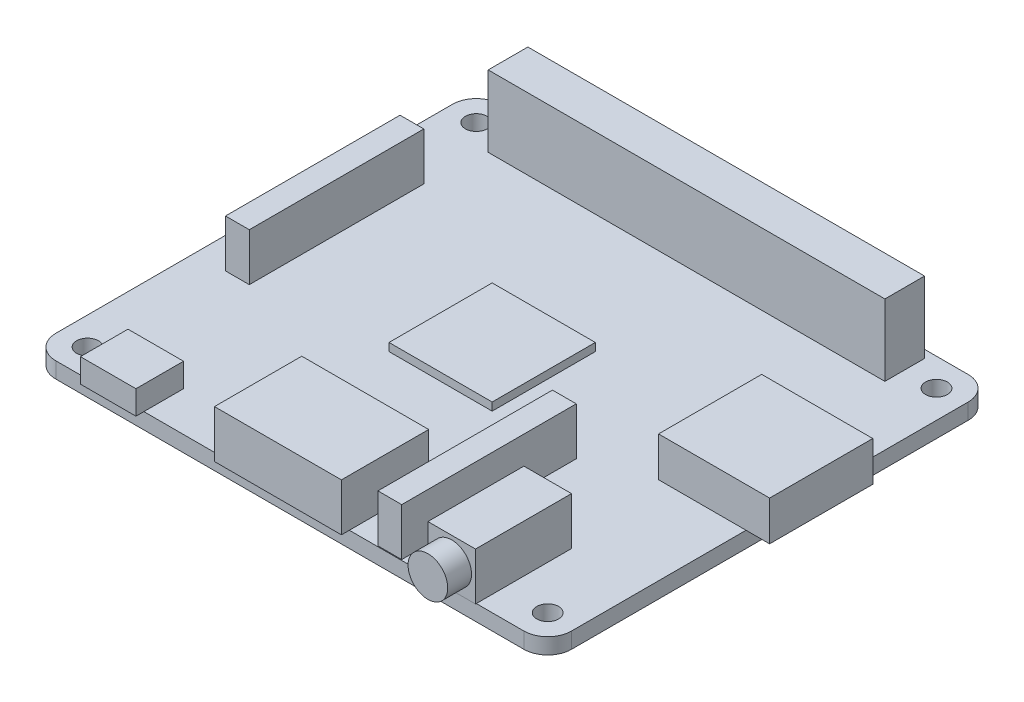
from build123d import *

# Parameters (mm, degrees)
SKETCH1_W            = 65
SKETCH1_H            = 56
BOSS_EXTRUDE1_DEPTH  = 2
SKETCH2_R            = 1.375
CUT_EXTRUDE1_DEPTH   = 2
FILLET1_R            = 3
FILLET2_R            = 3
FILLET3_R            = 3
FILLET4_R            = 3
SKETCH3_W            = 50
SKETCH3_H            = 5
BOSS_EXTRUDE2_DEPTH  = 9
SKETCH4_W            = 3
SKETCH4_H            = 22
BOSS_EXTRUDE3_DEPTH  = 6
SKETCH5_W            = 14
SKETCH5_H            = 13
BOSS_EXTRUDE4_DEPTH  = 5
SKETCH6_W            = 6
SKETCH6_H            = 12.1
BOSS_EXTRUDE5_DEPTH  = 6
SKETCH7_R            = 2.5
BOSS_EXTRUDE6_DEPTH  = 3
SKETCH8_W            = 3
SKETCH8_H            = 22
BOSS_EXTRUDE7_DEPTH  = 6
SKETCH9_W            = 16
SKETCH9_H            = 11
BOSS_EXTRUDE8_DEPTH  = 6
SKETCH10_W           = 7
SKETCH10_H           = 6
BOSS_EXTRUDE9_DEPTH  = 3
SKETCH11_W           = 17
SKETCH11_H           = 13
BOSS_EXTRUDE10_DEPTH = 2
SKETCH12_W           = 13
SKETCH12_H           = 13
BOSS_EXTRUDE11_DEPTH = 1


with BuildPart() as part:
    # Sketch1 → Boss-Extrude1 (new body)
    with BuildSketch(Plane(origin=(0, 0, 0), x_dir=(1, 0, 0), z_dir=(0, 1, 0))):
        Rectangle(SKETCH1_W, SKETCH1_H)
    extrude(amount=BOSS_EXTRUDE1_DEPTH)

    # Sketch2 → Cut-Extrude1 (cut)
    with BuildSketch(Plane(origin=(0, 2, 0), x_dir=(1, 0, 0), z_dir=(0, 1, 0))):
        with Locations((-29, -24.5)):
            Circle(SKETCH2_R)
        with Locations((-29, 24.5)):
            Circle(SKETCH2_R)
        with Locations((29, -24.5)):
            Circle(SKETCH2_R)
        with Locations((29, 24.5)):
            Circle(SKETCH2_R)
    extrude(amount=-CUT_EXTRUDE1_DEPTH, mode=Mode.SUBTRACT)

    # Fillet1
    fillet1_edges = [part.edges().sort_by_distance(p)[0] for p in [
        (-32.5, 1, 28),
    ]]
    fillet(fillet1_edges, radius=FILLET1_R)

    # Fillet2
    fillet2_edges = [part.edges().sort_by_distance(p)[0] for p in [
        (32.5, 1, 28),
    ]]
    fillet(fillet2_edges, radius=FILLET2_R)

    # Fillet3
    fillet3_edges = [part.edges().sort_by_distance(p)[0] for p in [
        (32.5, 1, -28),
    ]]
    fillet(fillet3_edges, radius=FILLET3_R)

    # Fillet4
    fillet4_edges = [part.edges().sort_by_distance(p)[0] for p in [
        (-32.5, 1, -28),
    ]]
    fillet(fillet4_edges, radius=FILLET4_R)

    # Sketch3 → Boss-Extrude2 (add)
    with BuildSketch(Plane(origin=(0, 2, 0), x_dir=(1, 0, 0), z_dir=(0, 1, 0))):
        with Locations((0, 24.5)):
            Rectangle(SKETCH3_W, SKETCH3_H)
    extrude(amount=BOSS_EXTRUDE2_DEPTH)

    # Sketch4 → Boss-Extrude3 (add)
    with BuildSketch(Plane(origin=(0, 2, 0), x_dir=(1, 0, 0), z_dir=(0, 1, 0))):
        with Locations((-27.111657831, 3.5)):
            Rectangle(SKETCH4_W, SKETCH4_H)
    extrude(amount=BOSS_EXTRUDE3_DEPTH)

    # Sketch5 → Boss-Extrude4 (add)
    with BuildSketch(Plane(origin=(0, 2, 0), x_dir=(1, 0, 0), z_dir=(0, 1, 0))):
        with Locations((28.469915967, 3.5)):
            Rectangle(SKETCH5_W, SKETCH5_H)
    extrude(amount=BOSS_EXTRUDE4_DEPTH)

    # Sketch6 → Boss-Extrude5 (add)
    with BuildSketch(Plane(origin=(0, 2, 0), x_dir=(1, 0, 0), z_dir=(0, 1, 0))):
        with Locations((20.5, -22.05)):
            Rectangle(SKETCH6_W, SKETCH6_H)
    extrude(amount=BOSS_EXTRUDE5_DEPTH)

    # Sketch7 → Boss-Extrude6 (add)
    with BuildSketch(Plane.XY.offset(28.1)):
        with Locations((20.5, 5)):
            Circle(SKETCH7_R)
    extrude(amount=BOSS_EXTRUDE6_DEPTH)

    # Sketch8 → Boss-Extrude7 (add)
    with BuildSketch(Plane(origin=(0, 2, 0), x_dir=(1, 0, 0), z_dir=(0, 1, 0))):
        with Locations((12.5, -16.9)):
            Rectangle(SKETCH8_W, SKETCH8_H)
    extrude(amount=BOSS_EXTRUDE7_DEPTH)

    # Sketch9 → Boss-Extrude8 (add)
    with BuildSketch(Plane(origin=(0, 2, 0), x_dir=(1, 0, 0), z_dir=(0, 1, 0))):
        with Locations((-0.5, -23.5)):
            Rectangle(SKETCH9_W, SKETCH9_H)
    extrude(amount=BOSS_EXTRUDE8_DEPTH)

    # Sketch10 → Boss-Extrude9 (add)
    with BuildSketch(Plane(origin=(0, 2, 0), x_dir=(1, 0, 0), z_dir=(0, 1, 0))):
        with Locations((-21.9, -26)):
            Rectangle(SKETCH10_W, SKETCH10_H)
    extrude(amount=BOSS_EXTRUDE9_DEPTH)

    # Sketch11 → Boss-Extrude10 (add)
    with BuildSketch(Plane.XZ):
        with Locations((-26, -1.5)):
            Rectangle(SKETCH11_W, SKETCH11_H)
    extrude(amount=BOSS_EXTRUDE10_DEPTH)

    # Sketch12 → Boss-Extrude11 (add)
    with BuildSketch(Plane(origin=(0, 2, 0), x_dir=(1, 0, 0), z_dir=(0, 1, 0))):
        with Locations((-3, 0.5)):
            Rectangle(SKETCH12_W, SKETCH12_H)
    extrude(amount=BOSS_EXTRUDE11_DEPTH)


solid = part.part
